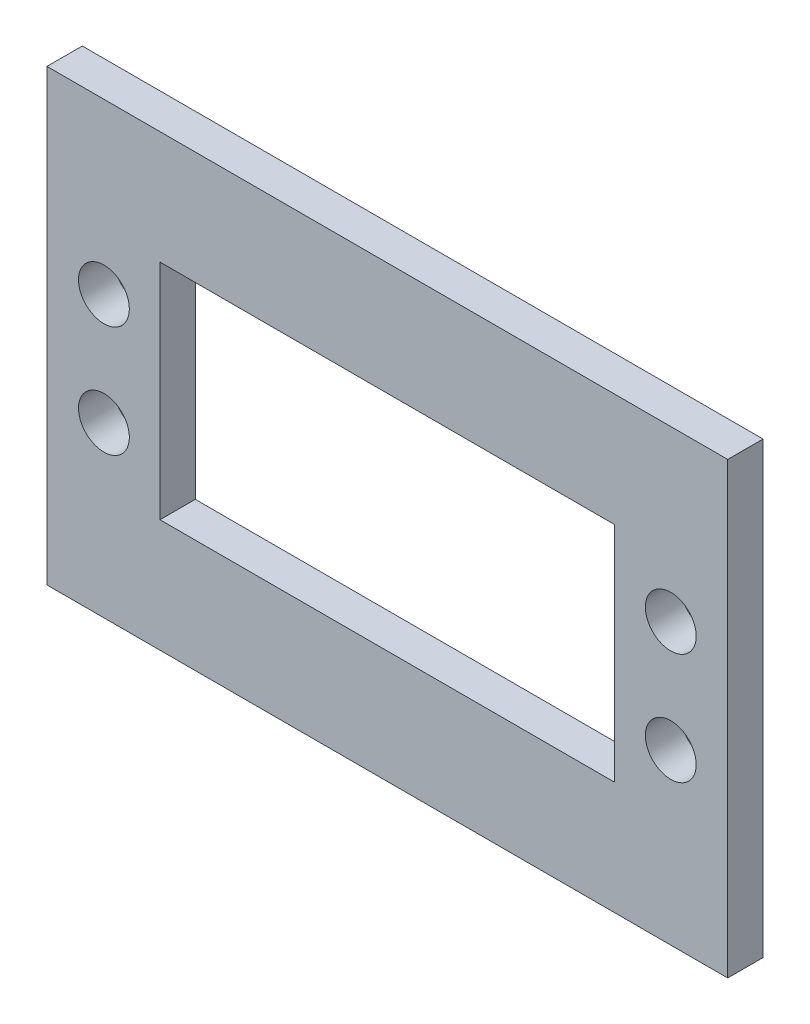
from build123d import *

# Parameters (mm, degrees)
SKETCH1_W           = 61.214
SKETCH1_H           = 40.386
SKETCH1_W_2         = 40.894
SKETCH1_H_2         = 20.066
BOSS_EXTRUDE1_DEPTH = 3.175
SKETCH2_R           = 2.286
CUT_EXTRUDE1_DEPTH  = 4.175


with BuildPart() as part:
    # Sketch1 → Boss-Extrude1 (new body)
    with BuildSketch(Plane.XY):
        with Locations((20.447, 10.033)):
            Rectangle(SKETCH1_W, SKETCH1_H)
        with Locations((20.447, 10.033)):
            Rectangle(SKETCH1_W_2, SKETCH1_H_2, mode=Mode.SUBTRACT)
    extrude(amount=BOSS_EXTRUDE1_DEPTH)

    # Sketch2 → Cut-Extrude1 (cut, through all)
    with BuildSketch(Plane.XY.offset(3.175)):
        with Locations((-5.04, 15.033)):
            Circle(SKETCH2_R)
        with Locations((-5.04, 5.033)):
            Circle(SKETCH2_R)
        with Locations((45.934, 5.033)):
            Circle(SKETCH2_R)
        with Locations((45.934, 15.033)):
            Circle(SKETCH2_R)
    extrude(amount=-CUT_EXTRUDE1_DEPTH, mode=Mode.SUBTRACT)


solid = part.part
